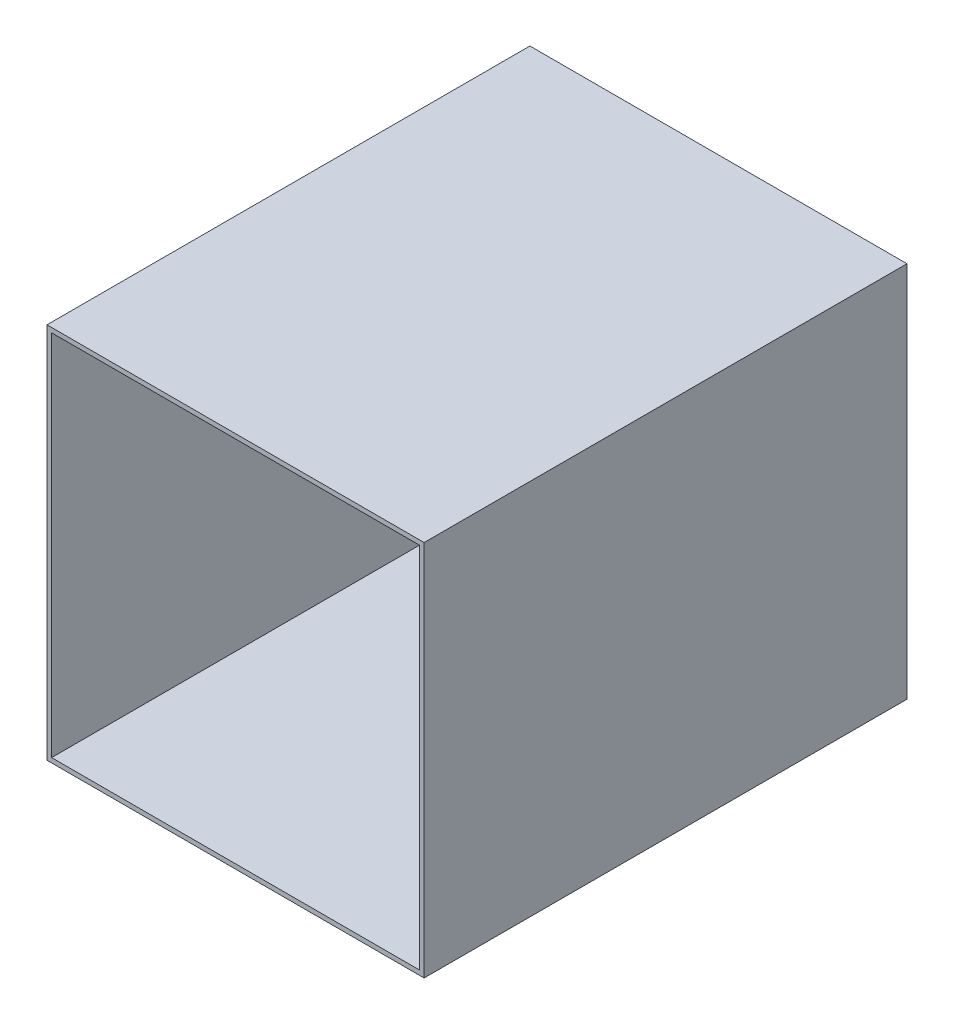
from build123d import *

# Parameters (mm, degrees)
SKETCH1_W           = 260.35
SKETCH1_H           = 260.35
SKETCH1_W_2         = 254
SKETCH1_H_2         = 254
BOSS_EXTRUDE1_DEPTH = 330.2
SKETCH1_2_W         = 260.35
SKETCH1_2_H         = 260.35
BOSS_EXTRUDE2_DEPTH = 3.175


with BuildPart() as part:
    # Sketch1 → Boss-Extrude1 (new body)
    with BuildSketch(Plane.XY):
        with Locations((127, 127)):
            Rectangle(SKETCH1_W, SKETCH1_H)
        with Locations((127, 127)):
            Rectangle(SKETCH1_W_2, SKETCH1_H_2, mode=Mode.SUBTRACT)
    extrude(amount=BOSS_EXTRUDE1_DEPTH)

    # Sketch1_2 → Boss-Extrude2 (add)
    with BuildSketch(Plane.XY):
        with Locations((127, 127)):
            Rectangle(SKETCH1_2_W, SKETCH1_2_H)
    extrude(amount=-BOSS_EXTRUDE2_DEPTH)


solid = part.part
